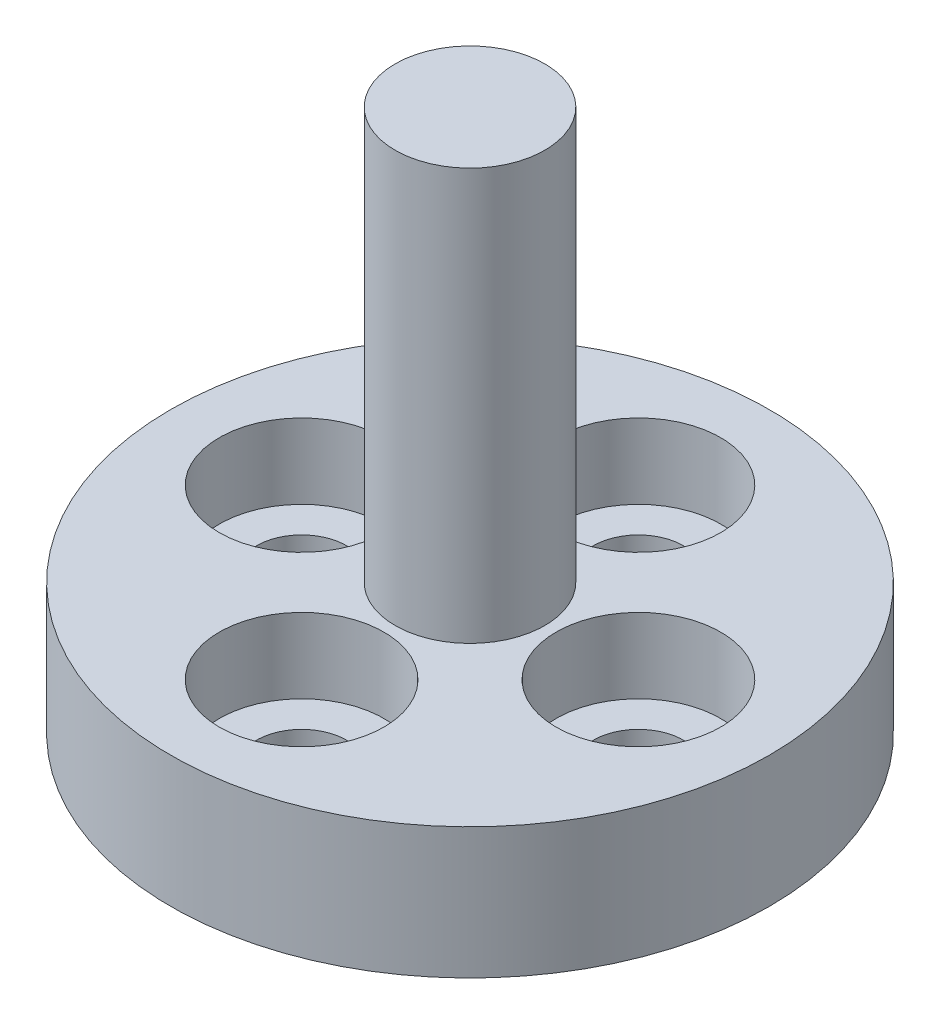
from build123d import *

# Parameters (mm, degrees)
CBORE_FOR_M2_SHCS1_D           = 2.4
CBORE_FOR_M2_SHCS1_CBORE_D     = 4.4
CBORE_FOR_M2_SHCS1_CBORE_DEPTH = 2


with BuildPart() as part:
    # Sketch1 → Revolve1 (revolve)
    with BuildSketch(Plane.XY):
        Polygon((0, 0), (8, 0), (8, 3.5), (2, 3.5), (2, 14.5), (0, 14.5), align=None)
    revolve(axis=Axis((0, 14.5, 0), (0, -1, 0)))

    # CBORE for M2 SHCS1 (through all)
    with Locations(Plane(origin=(0, 3.5, 0), x_dir=(1, 0, 0), z_dir=(0, 1, 0))):
        with Locations((-4.5, 0), (0, 4.5), (4.5, 0), (0, -4.5)):
            CounterBoreHole(CBORE_FOR_M2_SHCS1_D / 2, CBORE_FOR_M2_SHCS1_CBORE_D / 2, CBORE_FOR_M2_SHCS1_CBORE_DEPTH)


solid = part.part
